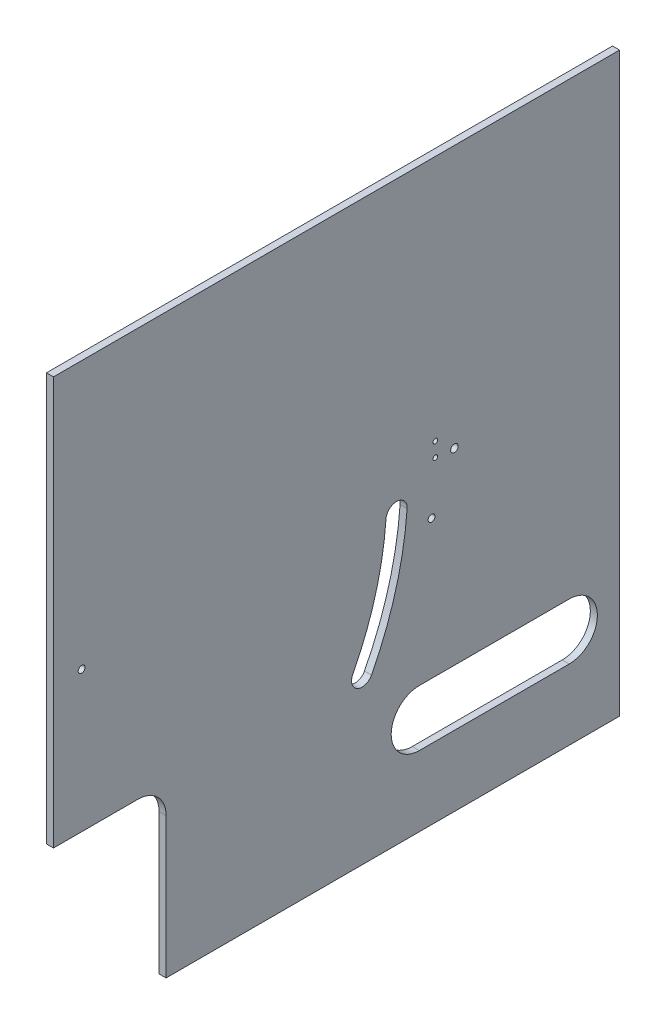
from build123d import *

# Parameters (mm, degrees)
SKETCH1_W           = 255.45
SKETCH1_H           = 260.35
BOSS_EXTRUDE1_DEPTH = 3.175
SKETCH2_W           = 255.45
SKETCH2_H           = 6.35
BOSS_EXTRUDE2_DEPTH = 12.7
CUT_EXTRUDE1_DEPTH  = 16.875
SKETCH5_W           = 54.590141408
SKETCH5_H           = 33.859166417
CUT_EXTRUDE2_DEPTH  = 256.45
SKETCH8_R           = 1.55
SKETCH8_R_2         = 1.6999966
SKETCH8_R_3         = 1.5499969
SKETCH8_R_4         = 1.05
CUT_EXTRUDE7_DEPTH  = 4.175
SKETCH9_W           = 50.8
SKETCH9_H           = 76.2
CUT_EXTRUDE8_DEPTH  = 4.175
FILLET1_R           = 12.7
CUT_EXTRUDE9_DEPTH  = 4.175


with BuildPart() as part:
    # Sketch1 → Boss-Extrude1 (new body)
    with BuildSketch(Plane(origin=(0, 0, 0), x_dir=(0, 0, -1), z_dir=(1, 0, 0))):
        Rectangle(SKETCH1_W, SKETCH1_H)
    extrude(amount=BOSS_EXTRUDE1_DEPTH)

    # Sketch2 → Boss-Extrude2 (add)
    with BuildSketch(Plane(origin=(3.175, 0, 0), x_dir=(0, 0, -1), z_dir=(1, 0, 0))):
        with Locations((0, 127)):
            Rectangle(SKETCH2_W, SKETCH2_H)
    extrude(amount=BOSS_EXTRUDE2_DEPTH)

    # Sketch3 → Cut-Extrude1 (cut, through all)
    with BuildSketch(Plane.ZY):
        with BuildLine():
            Line((-105.025, -73.025), (-37.375, -73.025))
            ThreePointArc((-37.375, -73.025), (-24.675, -85.725), (-37.375, -98.425))
            Line((-37.375, -98.425), (-105.025, -98.425))
            ThreePointArc((-105.025, -98.425), (-117.725, -85.725), (-105.025, -73.025))
        make_face()
    extrude(amount=-CUT_EXTRUDE1_DEPTH, mode=Mode.SUBTRACT)

    # Sketch5 → Cut-Extrude2 (cut, through all)
    with BuildSketch(Plane(origin=(0, 0, -127.725), x_dir=(-1, 0, 0), z_dir=(0, 0, -1))):
        with Locations((-30.470070704, 140.754583209)):
            Rectangle(SKETCH5_W, SKETCH5_H)
    extrude(amount=-CUT_EXTRUDE2_DEPTH, mode=Mode.SUBTRACT)

    # Sketch8 → Cut-Extrude7 (cut, through all)
    with BuildSketch(Plane.ZY):
        with Locations((115.025, 9.525)):
            Circle(SKETCH8_R)
        with Locations((-53.205, 11.825)):
            Circle(SKETCH8_R_2)
        with Locations((-42.9049952, -10.375)):
            Circle(SKETCH8_R_3)
        with Locations((-44.605, 18.925)):
            Circle(SKETCH8_R_4)
        with Locations((-44.605, 12.425)):
            Circle(SKETCH8_R_4)
    extrude(amount=-CUT_EXTRUDE7_DEPTH, mode=Mode.SUBTRACT)

    # Sketch9 → Cut-Extrude8 (cut, through all)
    with BuildSketch(Plane.ZY):
        with Locations((102.325, -92.075)):
            Rectangle(SKETCH9_W, SKETCH9_H)
    extrude(amount=-CUT_EXTRUDE8_DEPTH, mode=Mode.SUBTRACT)

    # Fillet1
    fillet1_edges = [part.edges().sort_by_distance(p)[0] for p in [
        (1.5875, -53.975, 76.925),
    ]]
    fillet(fillet1_edges, radius=FILLET1_R)

    # Sketch10 → Cut-Extrude9 (cut, through all)
    with BuildSketch(Plane.ZY):
        with BuildLine():
            ThreePointArc((-15.792035743, -58.127079483), (-9.357313119, -60.175), (-7.309392602, -53.740277376))
            ThreePointArc((-7.309392602, -53.740277376), (-17.536268555, -27.834189149), (-22.341982218, -0.400277376))
            ThreePointArc((-22.341982218, -0.400277376), (-27.448590626, 4.018114216), (-31.866982218, -1.088494191))
            ThreePointArc((-31.866982218, -1.088494191), (-26.728041298, -30.424668105), (-15.792035743, -58.127079483))
        make_face()
    extrude(amount=-CUT_EXTRUDE9_DEPTH, mode=Mode.SUBTRACT)


solid = part.part
